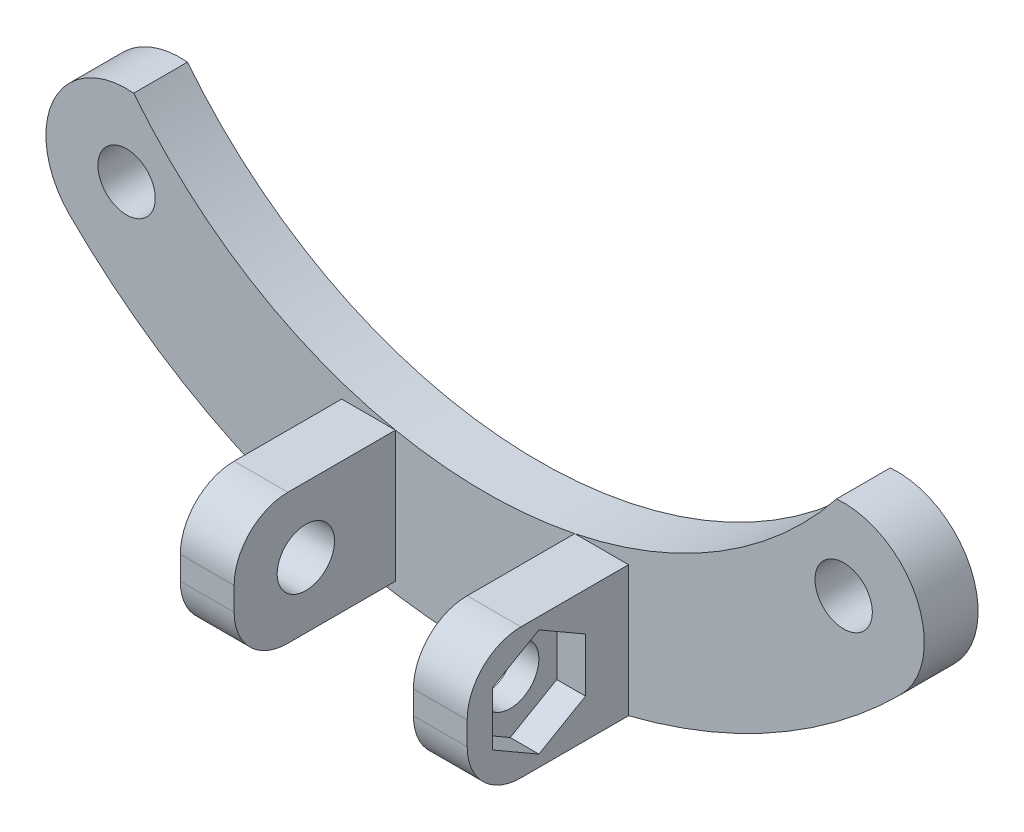
from build123d import *

# Parameters (mm, degrees)
CROQUIS1_R              = 1.6
SALIENTE_EXTRUIR1_DEPTH = 3
CROQUIS2_W              = 3
CROQUIS2_H              = 7.298316333
SALIENTE_EXTRUIR2_DEPTH = 9
CROQUIS3_R              = 1.6
CORTAR_EXTRUIR1_DEPTH   = 16
CORTAR_EXTRUIR2_DEPTH   = 1.6
REDONDEO1_R             = 3


with BuildPart() as part:
    # Croquis1 → Saliente-Extruir1 (new body)
    with BuildSketch(Plane.XY):
        with BuildLine():
            ThreePointArc((0.398971354, 4.482278646), (-4.076947647, 1.904861643), (-3.181980515, -3.181980515))
            ThreePointArc((-3.181980515, -3.181980515), (20, -12.784271247), (43.181980515, -3.181980515))
            ThreePointArc((43.181980515, -3.181980515), (44.076947647, 1.904861643), (39.601028646, 4.482278646))
            ThreePointArc((39.601028646, 4.482278646), (20, -5), (0.398971354, 4.482278646))
        make_face()
        Circle(CROQUIS1_R, mode=Mode.SUBTRACT)
        with Locations((40, 0)):
            Circle(CROQUIS1_R, mode=Mode.SUBTRACT)
    extrude(amount=SALIENTE_EXTRUIR1_DEPTH)

    # Croquis2 → Saliente-Extruir2 (add)
    with BuildSketch(Plane.XY.offset(3)):
        with Locations((13.5, -8.144055595)):
            Rectangle(CROQUIS2_W, CROQUIS2_H)
        with Locations((26.5, -8.144055595)):
            Rectangle(CROQUIS2_W, CROQUIS2_H)
    extrude(amount=SALIENTE_EXTRUIR2_DEPTH)

    # Croquis3 → Cortar-Extruir1 (cut)
    with BuildSketch(Plane.ZY.offset(-12)):
        with Locations((8, -8.144897428)):
            Circle(CROQUIS3_R)
    extrude(amount=-CORTAR_EXTRUIR1_DEPTH, mode=Mode.SUBTRACT)

    # Croquis4 → Cortar-Extruir2 (cut)
    with BuildSketch(Plane(origin=(28, 0, 0), x_dir=(0, 0, -1), z_dir=(1, 0, 0))):
        Polygon((-5.401923789, -9.644897428), (-5.401923789, -6.644897428), (-8, -5.144897428), (-10.598076211, -6.644897428), (-10.598076211, -9.644897428), (-8, -11.144897428), align=None)
    extrude(amount=-CORTAR_EXTRUIR2_DEPTH, mode=Mode.SUBTRACT)

    # Redondeo1
    redondeo1_edges = [part.edges().sort_by_distance(p)[0] for p in [
        (13.5, -11.793213761, 12),
        (13.5, -4.494897428, 12),
        (26.5, -4.494897428, 12),
        (26.5, -11.793213761, 12),
    ]]
    fillet(redondeo1_edges, radius=REDONDEO1_R)


solid = part.part
